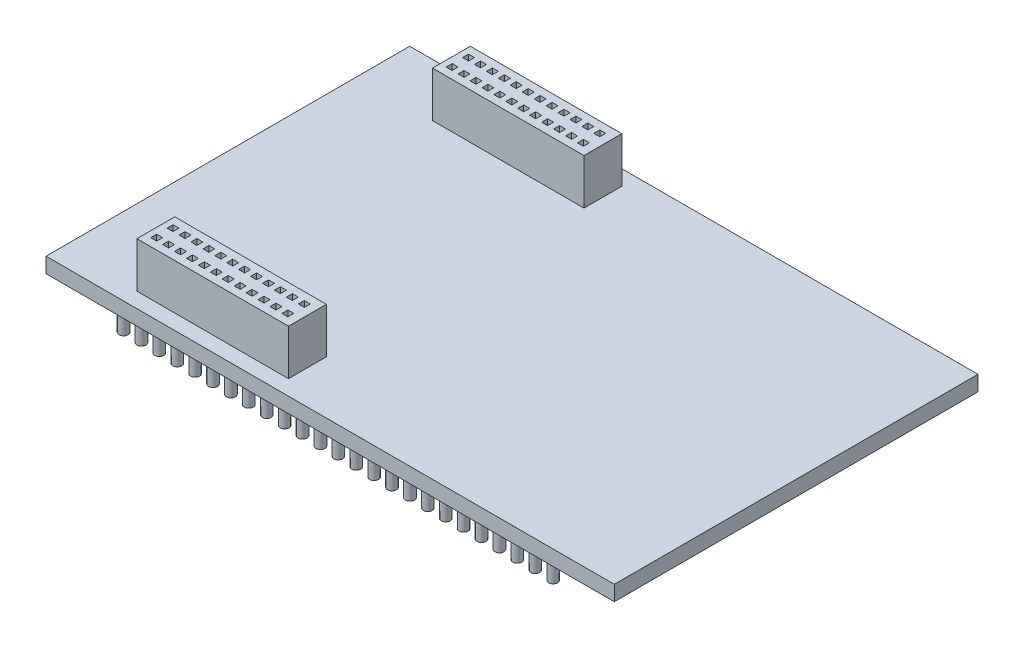
from build123d import *

# Parameters (mm, degrees)
SKETCH1_W           = 95.25
SKETCH1_H           = 60.96
BOSS_EXTRUDE1_DEPTH = 2.54
SKETCH2_W           = 25.4
SKETCH2_H           = 6.35
BOSS_EXTRUDE2_DEPTH = 7.62
SKETCH3_W           = 1
SKETCH3_H           = 1
CUT_EXTRUDE1_DEPTH  = 4.62
SKETCH4_R           = 0.75
BOSS_EXTRUDE3_DEPTH = 5


with BuildPart() as part:
    # Sketch1 → Boss-Extrude1 (new body)
    with BuildSketch(Plane(origin=(0, 0, 0), x_dir=(1, 0, 0), z_dir=(0, 1, 0))):
        with Locations((47.625, 30.48)):
            Rectangle(SKETCH1_W, SKETCH1_H)
    extrude(amount=BOSS_EXTRUDE1_DEPTH)

    # Sketch2 → Boss-Extrude2 (add)
    with BuildSketch(Plane(origin=(0, 2.54, 0), x_dir=(1, 0, 0), z_dir=(0, 1, 0))):
        with Locations((25.4, 55.245)):
            Rectangle(SKETCH2_W, SKETCH2_H)
        with Locations((25.4, 5.715)):
            Rectangle(SKETCH2_W, SKETCH2_H)
    extrude(amount=BOSS_EXTRUDE2_DEPTH)

    # Sketch3 → Cut-Extrude1 (cut)
    with BuildSketch(Plane(origin=(0, 10.16, 0), x_dir=(1, 0, 0), z_dir=(0, 1, 0))):
        with Locations((14.2, 56.62)):
            Rectangle(SKETCH3_W, SKETCH3_H)
        with Locations((16.2, 56.62)):
            Rectangle(SKETCH3_W, SKETCH3_H)
        with Locations((18.2, 56.62)):
            Rectangle(SKETCH3_W, SKETCH3_H)
        with Locations((20.2, 56.62)):
            Rectangle(SKETCH3_W, SKETCH3_H)
        with Locations((22.2, 56.62)):
            Rectangle(SKETCH3_W, SKETCH3_H)
        with Locations((24.2, 56.62)):
            Rectangle(SKETCH3_W, SKETCH3_H)
        with Locations((26.2, 56.62)):
            Rectangle(SKETCH3_W, SKETCH3_H)
        with Locations((28.2, 56.62)):
            Rectangle(SKETCH3_W, SKETCH3_H)
        with Locations((30.2, 56.62)):
            Rectangle(SKETCH3_W, SKETCH3_H)
        with Locations((32.2, 56.62)):
            Rectangle(SKETCH3_W, SKETCH3_H)
        with Locations((34.2, 56.62)):
            Rectangle(SKETCH3_W, SKETCH3_H)
        with Locations((36.2, 56.62)):
            Rectangle(SKETCH3_W, SKETCH3_H)
        with Locations((36.2, 53.87)):
            Rectangle(SKETCH3_W, SKETCH3_H)
        with Locations((34.2, 53.87)):
            Rectangle(SKETCH3_W, SKETCH3_H)
        with Locations((32.2, 53.87)):
            Rectangle(SKETCH3_W, SKETCH3_H)
        with Locations((30.2, 53.87)):
            Rectangle(SKETCH3_W, SKETCH3_H)
        with Locations((28.2, 53.87)):
            Rectangle(SKETCH3_W, SKETCH3_H)
        with Locations((26.2, 53.87)):
            Rectangle(SKETCH3_W, SKETCH3_H)
        with Locations((24.2, 53.87)):
            Rectangle(SKETCH3_W, SKETCH3_H)
        with Locations((22.2, 53.87)):
            Rectangle(SKETCH3_W, SKETCH3_H)
        with Locations((20.2, 53.87)):
            Rectangle(SKETCH3_W, SKETCH3_H)
        with Locations((18.2, 53.87)):
            Rectangle(SKETCH3_W, SKETCH3_H)
        with Locations((16.2, 53.87)):
            Rectangle(SKETCH3_W, SKETCH3_H)
        with Locations((14.2, 53.87)):
            Rectangle(SKETCH3_W, SKETCH3_H)
    cut_extrude1 = extrude(amount=-CUT_EXTRUDE1_DEPTH, mode=Mode.SUBTRACT)

    # Mirror1: Cut-Extrude1 across plane
    add(cut_extrude1.mirror(Plane.XY.offset(-30.48)), mode=Mode.SUBTRACT)

    # Sketch4 → Boss-Extrude3 (add)
    with BuildSketch(Plane.XZ):
        with Locations((10, -3)):
            Circle(SKETCH4_R)
        with Locations((13, -3)):
            Circle(SKETCH4_R)
        with Locations((16, -3)):
            Circle(SKETCH4_R)
        with Locations((19, -3)):
            Circle(SKETCH4_R)
        with Locations((22, -3)):
            Circle(SKETCH4_R)
        with Locations((25, -3)):
            Circle(SKETCH4_R)
        with Locations((28, -3)):
            Circle(SKETCH4_R)
        with Locations((31, -3)):
            Circle(SKETCH4_R)
        with Locations((34, -3)):
            Circle(SKETCH4_R)
        with Locations((37, -3)):
            Circle(SKETCH4_R)
        with Locations((40, -3)):
            Circle(SKETCH4_R)
        with Locations((43, -3)):
            Circle(SKETCH4_R)
        with Locations((46, -3)):
            Circle(SKETCH4_R)
        with Locations((49, -3)):
            Circle(SKETCH4_R)
        with Locations((52, -3)):
            Circle(SKETCH4_R)
        with Locations((55, -3)):
            Circle(SKETCH4_R)
        with Locations((58, -3)):
            Circle(SKETCH4_R)
        with Locations((61, -3)):
            Circle(SKETCH4_R)
        with Locations((64, -3)):
            Circle(SKETCH4_R)
        with Locations((67, -3)):
            Circle(SKETCH4_R)
        with Locations((70, -3)):
            Circle(SKETCH4_R)
        with Locations((73, -3)):
            Circle(SKETCH4_R)
        with Locations((76, -3)):
            Circle(SKETCH4_R)
        with Locations((79, -3)):
            Circle(SKETCH4_R)
        with Locations((82, -3)):
            Circle(SKETCH4_R)
        with Locations((13, -8)):
            Circle(SKETCH4_R)
        with Locations((16, -8)):
            Circle(SKETCH4_R)
        with Locations((19, -8)):
            Circle(SKETCH4_R)
        with Locations((22, -8)):
            Circle(SKETCH4_R)
        with Locations((25, -8)):
            Circle(SKETCH4_R)
        with Locations((28, -8)):
            Circle(SKETCH4_R)
        with Locations((31, -8)):
            Circle(SKETCH4_R)
        with Locations((34, -8)):
            Circle(SKETCH4_R)
        with Locations((37, -8)):
            Circle(SKETCH4_R)
        with Locations((40, -8)):
            Circle(SKETCH4_R)
        with Locations((43, -8)):
            Circle(SKETCH4_R)
        with Locations((46, -8)):
            Circle(SKETCH4_R)
        with Locations((49, -8)):
            Circle(SKETCH4_R)
        with Locations((52, -8)):
            Circle(SKETCH4_R)
        with Locations((55, -8)):
            Circle(SKETCH4_R)
        with Locations((58, -8)):
            Circle(SKETCH4_R)
        with Locations((61, -8)):
            Circle(SKETCH4_R)
        with Locations((64, -8)):
            Circle(SKETCH4_R)
        with Locations((67, -8)):
            Circle(SKETCH4_R)
        with Locations((70, -8)):
            Circle(SKETCH4_R)
        with Locations((73, -8)):
            Circle(SKETCH4_R)
        with Locations((76, -8)):
            Circle(SKETCH4_R)
        with Locations((79, -8)):
            Circle(SKETCH4_R)
        with Locations((82, -8)):
            Circle(SKETCH4_R)
        with Locations((10, -8)):
            Circle(SKETCH4_R)
        with Locations((10, -52.96)):
            Circle(SKETCH4_R)
        with Locations((82, -52.96)):
            Circle(SKETCH4_R)
        with Locations((79, -52.96)):
            Circle(SKETCH4_R)
        with Locations((76, -52.96)):
            Circle(SKETCH4_R)
        with Locations((73, -52.96)):
            Circle(SKETCH4_R)
        with Locations((70, -52.96)):
            Circle(SKETCH4_R)
        with Locations((67, -52.96)):
            Circle(SKETCH4_R)
        with Locations((64, -52.96)):
            Circle(SKETCH4_R)
        with Locations((61, -52.96)):
            Circle(SKETCH4_R)
        with Locations((58, -52.96)):
            Circle(SKETCH4_R)
        with Locations((55, -52.96)):
            Circle(SKETCH4_R)
        with Locations((52, -52.96)):
            Circle(SKETCH4_R)
        with Locations((49, -52.96)):
            Circle(SKETCH4_R)
        with Locations((46, -52.96)):
            Circle(SKETCH4_R)
        with Locations((43, -52.96)):
            Circle(SKETCH4_R)
        with Locations((40, -52.96)):
            Circle(SKETCH4_R)
        with Locations((37, -52.96)):
            Circle(SKETCH4_R)
        with Locations((34, -52.96)):
            Circle(SKETCH4_R)
        with Locations((31, -52.96)):
            Circle(SKETCH4_R)
        with Locations((28, -52.96)):
            Circle(SKETCH4_R)
        with Locations((25, -52.96)):
            Circle(SKETCH4_R)
        with Locations((22, -52.96)):
            Circle(SKETCH4_R)
        with Locations((19, -52.96)):
            Circle(SKETCH4_R)
        with Locations((16, -52.96)):
            Circle(SKETCH4_R)
        with Locations((13, -52.96)):
            Circle(SKETCH4_R)
        with Locations((82, -57.96)):
            Circle(SKETCH4_R)
        with Locations((79, -57.96)):
            Circle(SKETCH4_R)
        with Locations((76, -57.96)):
            Circle(SKETCH4_R)
        with Locations((73, -57.96)):
            Circle(SKETCH4_R)
        with Locations((70, -57.96)):
            Circle(SKETCH4_R)
        with Locations((67, -57.96)):
            Circle(SKETCH4_R)
        with Locations((64, -57.96)):
            Circle(SKETCH4_R)
        with Locations((61, -57.96)):
            Circle(SKETCH4_R)
        with Locations((58, -57.96)):
            Circle(SKETCH4_R)
        with Locations((55, -57.96)):
            Circle(SKETCH4_R)
        with Locations((52, -57.96)):
            Circle(SKETCH4_R)
        with Locations((49, -57.96)):
            Circle(SKETCH4_R)
        with Locations((46, -57.96)):
            Circle(SKETCH4_R)
        with Locations((43, -57.96)):
            Circle(SKETCH4_R)
        with Locations((40, -57.96)):
            Circle(SKETCH4_R)
        with Locations((37, -57.96)):
            Circle(SKETCH4_R)
        with Locations((34, -57.96)):
            Circle(SKETCH4_R)
        with Locations((31, -57.96)):
            Circle(SKETCH4_R)
        with Locations((28, -57.96)):
            Circle(SKETCH4_R)
        with Locations((25, -57.96)):
            Circle(SKETCH4_R)
        with Locations((22, -57.96)):
            Circle(SKETCH4_R)
        with Locations((19, -57.96)):
            Circle(SKETCH4_R)
        with Locations((16, -57.96)):
            Circle(SKETCH4_R)
        with Locations((13, -57.96)):
            Circle(SKETCH4_R)
        with Locations((10, -57.96)):
            Circle(SKETCH4_R)
    extrude(amount=BOSS_EXTRUDE3_DEPTH)


solid = part.part
